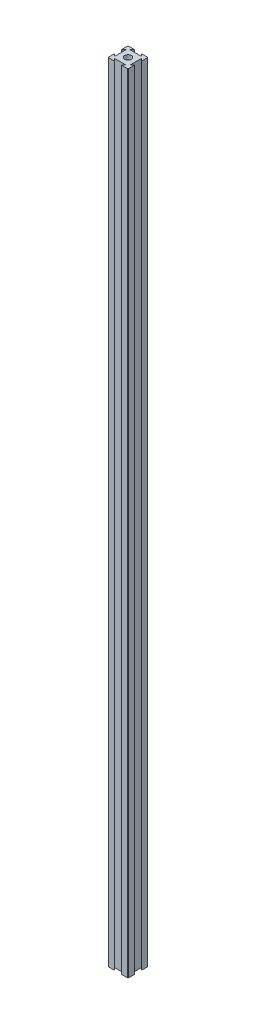
from build123d import *

# Parameters (mm, degrees)
SKETCH1_R           = 3.333333333
BOSS_EXTRUDE1_DEPTH = 787.4
FILLET4_R           = 0.508


with BuildPart() as part:
    # Sketch1 → Boss-Extrude1 (new body)
    with BuildSketch(Plane(origin=(0, 0, 0), x_dir=(1, 0, 0), z_dir=(0, 1, 0))):
        Polygon((4.285, 17.618333333), (6.666666667, 20), (0, 20), (0, 13.333333333), (2.381666667, 15.715), (2.381666667, 4.285), (0, 6.666666667), (0, 0), (6.666666667, 0), (4.285, 2.381666667), (15.715, 2.381666667), (13.333333333, 0), (20, 0), (20, 6.666666667), (17.618333333, 4.285), (17.618333333, 15.715), (20, 13.333333333), (20, 20), (13.333333333, 20), (15.715, 17.618333333), align=None)
        with Locations((10, 10)):
            Circle(SKETCH1_R, mode=Mode.SUBTRACT)
    extrude(amount=BOSS_EXTRUDE1_DEPTH)

    # Fillet4
    fillet4_edges = [part.edges().sort_by_distance(p)[0] for p in [
        (20, 393.7, 0),
        (0, 393.7, 0),
        (0, 393.7, -20),
        (20, 393.7, -20),
    ]]
    fillet(fillet4_edges, radius=FILLET4_R)


solid = part.part
